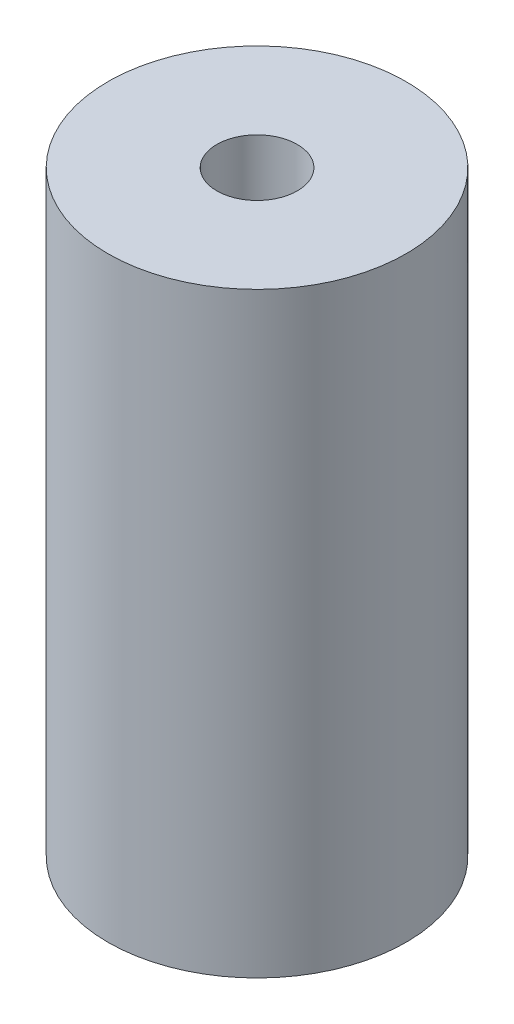
from build123d import *

# Parameters (mm, degrees)
SKETCH1_R           = 5
BOSS_EXTRUDE1_DEPTH = 20
SKETCH2_R           = 1.35
CUT_EXTRUDE1_DEPTH  = 6
SKETCH12_R          = 1.35
CUT_EXTRUDE2_DEPTH  = 10


with BuildPart() as part:
    # Sketch1 → Boss-Extrude1 (new body)
    with BuildSketch(Plane(origin=(0, 0, 0), x_dir=(1, 0, 0), z_dir=(0, 1, 0))):
        Circle(SKETCH1_R)
    extrude(amount=BOSS_EXTRUDE1_DEPTH)

    # Sketch2 → Cut-Extrude1 (cut)
    with BuildSketch(Plane(origin=(0, 20, 0), x_dir=(1, 0, 0), z_dir=(0, 1, 0))):
        Circle(SKETCH2_R)
    extrude(amount=-CUT_EXTRUDE1_DEPTH, mode=Mode.SUBTRACT)

    # Sketch12 → Cut-Extrude2 (cut)
    with BuildSketch(Plane.XZ):
        Circle(SKETCH12_R)
    extrude(amount=-CUT_EXTRUDE2_DEPTH, mode=Mode.SUBTRACT)


solid = part.part
